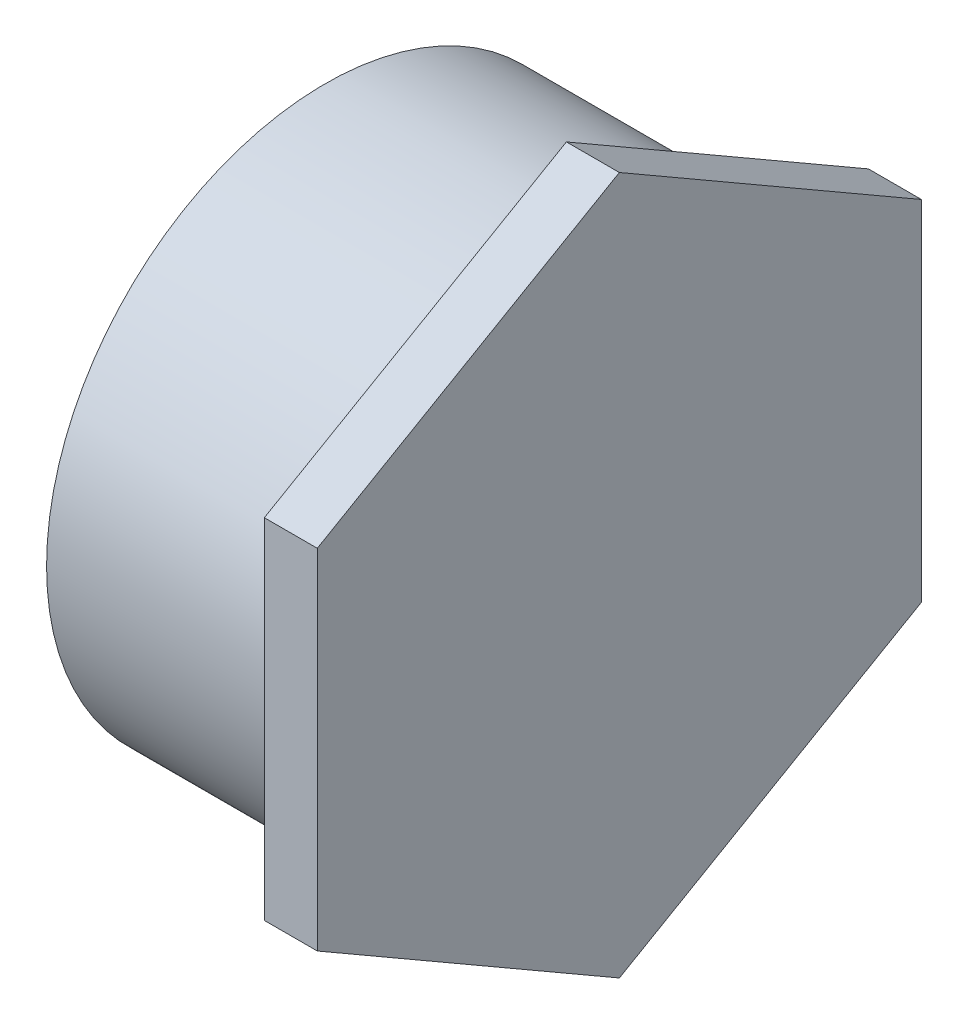
from build123d import *

# Parameters (mm, degrees)
BOSS_EXTRUDE1_DEPTH = 16.002


with BuildPart() as part:
    # Sketch1 → Revolve1 (revolve)
    with BuildSketch(Plane.XY):
        Polygon((-44.45, -84.1375), (28.448, -84.1375), (28.448, -91.2495), (44.45, -91.2495), (44.45, 0), (28.448, 0), (28.448, -77.0255), (-44.45, -77.0255), align=None)
    revolve(axis=Axis((-44.45, 0, 0), (1, 0, 0)))

    # Sketch2 → Boss-Extrude1 (add)
    with BuildSketch(Plane.ZY.offset(-28.448)):
        Polygon((-91.2495, 52.682923388), (-91.2495, -52.682923388), (0, -105.365846777), (91.2495, -52.682923388), (91.2495, 52.682923388), (0, 105.365846777), align=None)
    extrude(amount=-BOSS_EXTRUDE1_DEPTH)


solid = part.part
